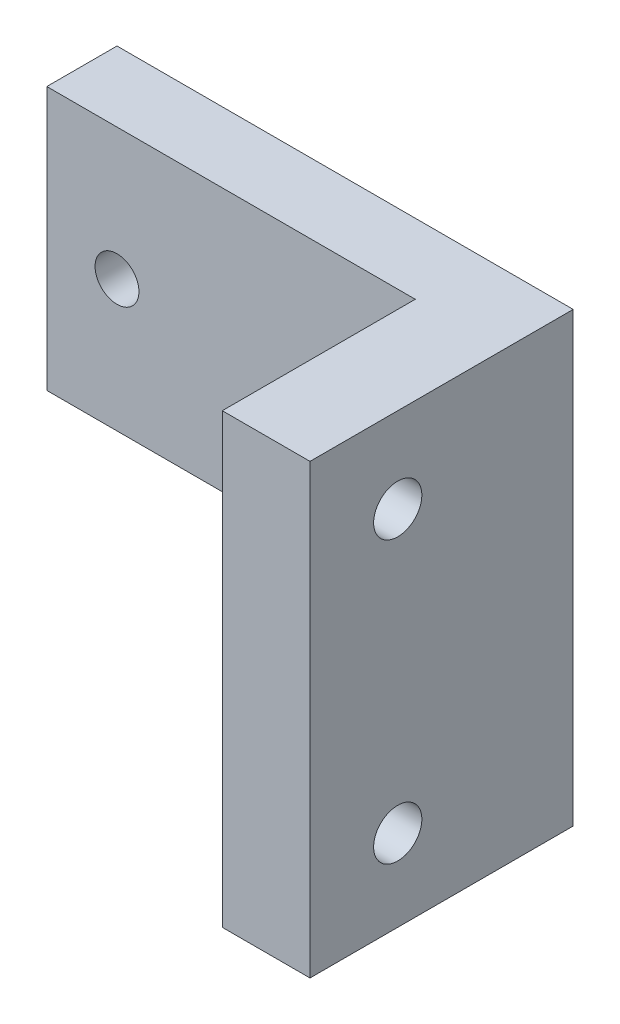
from build123d import *

# Parameters (mm, degrees)
SKETCH1_W             = 42
SKETCH1_H             = 30
BOSS_EXTRUDE1_DEPTH   = 8
BOSS_EXTRUDE1_2_DEPTH = 8
BOSS_EXTRUDE2_DEPTH   = 30
SKETCH2_R             = 2.5
CUT_EXTRUDE1_DEPTH    = 8
SKETCH3_R             = 2.75
CUT_EXTRUDE2_DEPTH    = 10
SKETCH6_W             = 30
SKETCH6_H             = 97
CUT_EXTRUDE6_DEPTH    = 52


with BuildPart() as part:
    # Sketch1 → Boss-Extrude1 (new body)
    with BuildSketch(Plane.XY):
        with Locations((21, 133)):
            Rectangle(SKETCH1_W, SKETCH1_H)
    extrude(amount=BOSS_EXTRUDE1_DEPTH)



with BuildPart() as body_2:
    # Sketch1 → Boss-Extrude1 2 (new body)
    with BuildSketch(Plane.XY):
        with Locations((21, 15)):
            Rectangle(SKETCH1_W, SKETCH1_H)
    extrude(amount=BOSS_EXTRUDE1_2_DEPTH)


with BuildPart() as part_1:
    add(part.part)

    add(body_2.part)  # Boss-Extrude2 merges body 2
    # Sketch1_3 → Boss-Extrude2 (add)
    with BuildSketch(Plane.XY):
        Polygon((42, 30), (42, 0), (52, 0), (52, 148), (42, 148), (42, 118), align=None)
    extrude(amount=BOSS_EXTRUDE2_DEPTH)

    # Sketch2 → Cut-Extrude1 (cut)
    with BuildSketch(Plane.XY.offset(8)):
        with Locations((8, 133)):
            Circle(SKETCH2_R)
        with Locations((34, 133)):
            Circle(SKETCH2_R)
        with Locations((34, 15)):
            Circle(SKETCH2_R)
        with Locations((8, 15)):
            Circle(SKETCH2_R)
    extrude(amount=-CUT_EXTRUDE1_DEPTH, mode=Mode.SUBTRACT)

    # Sketch3 → Cut-Extrude2 (cut)
    with BuildSketch(Plane(origin=(52, 0, 0), x_dir=(0, 0, -1), z_dir=(1, 0, 0))):
        with Locations((-20, 138.3)):
            Circle(SKETCH3_R)
        with Locations((-20, 106.3)):
            Circle(SKETCH3_R)
        with Locations((-20, 41.2)):
            Circle(SKETCH3_R)
        with Locations((-20, 9.2)):
            Circle(SKETCH3_R)
    extrude(amount=-CUT_EXTRUDE2_DEPTH, mode=Mode.SUBTRACT)

    # Sketch6 → Cut-Extrude6 (cut)
    with BuildSketch(Plane.ZY):
        with Locations((15, 48.5)):
            Rectangle(SKETCH6_W, SKETCH6_H)
    extrude(amount=-CUT_EXTRUDE6_DEPTH, mode=Mode.SUBTRACT)


solid = part_1.part
